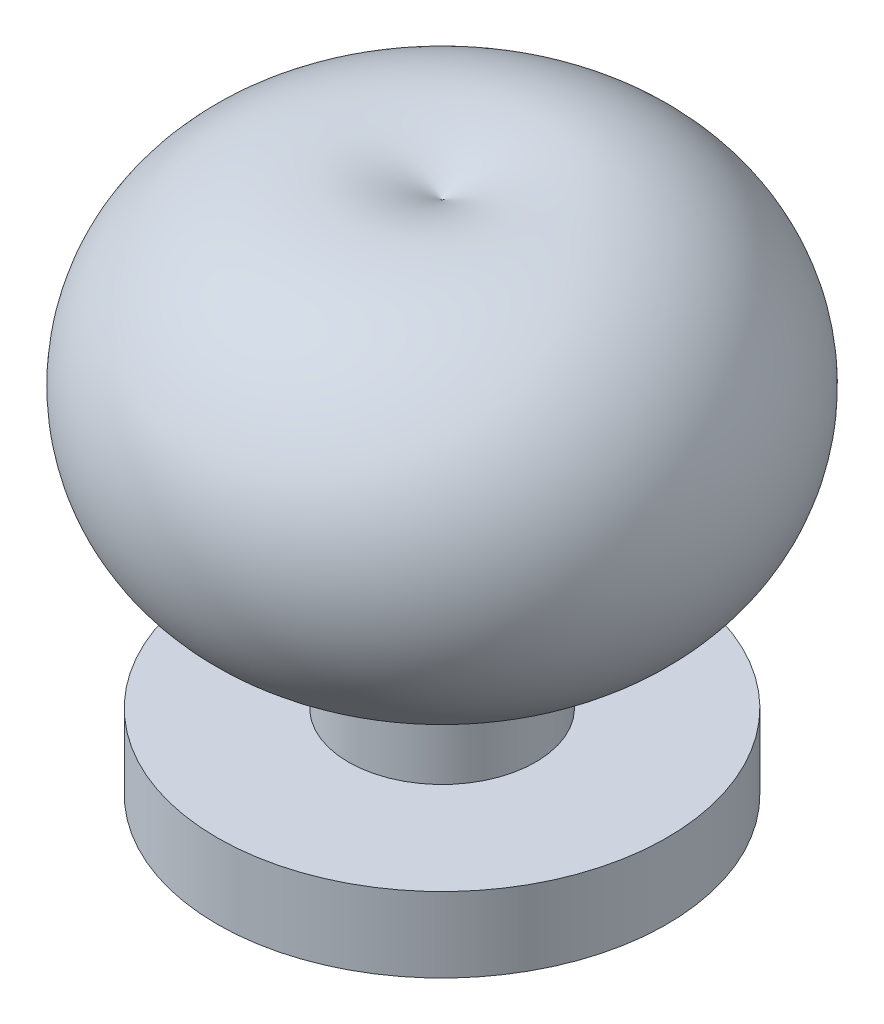
from build123d import *


with BuildPart() as part:
    # Sketch1 → Revolve1 (revolve)
    with BuildSketch(Plane(origin=(0, 0, 0), x_dir=(0, 0, -1), z_dir=(1, 0, 0))):
        with BuildLine():
            Line((0, 0), (6, 0))
            Line((6, 0), (6, 2))
            Line((6, 2), (2.5, 2))
            Line((2.5, 2), (2.5, 4.5))
            ThreePointArc((2.5, 4.5), (7.290941974, 10.75768702), (0, 13.75))
            Line((0, 13.75), (0, 0))
        make_face()
    revolve(axis=Axis((0, 13.75, 0), (0, -1, 0)))


solid = part.part
